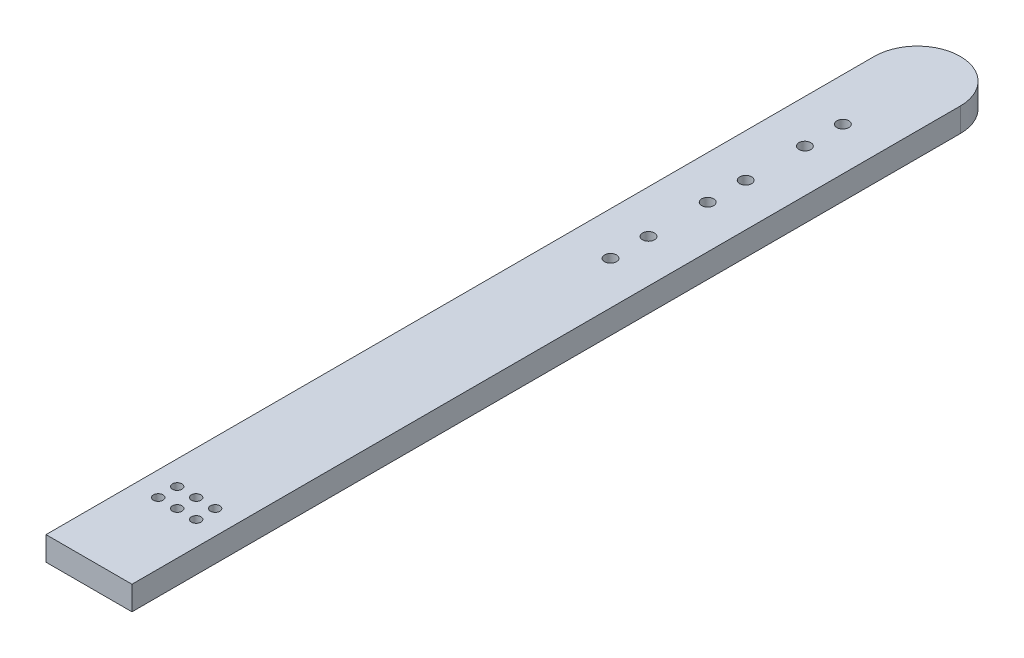
from build123d import *

# Parameters (mm, degrees)
BOSS_EXTRUDE1_DEPTH = 1.6
SKETCH2_R           = 0.3175
SKETCH2_R_2         = 0.4
CUT_EXTRUDE1_DEPTH  = 39.259239815


with BuildPart() as part:
    # Sketch1 → Boss-Extrude1 (new body)
    with BuildSketch(Plane(origin=(0, 0, 0), x_dir=(1, 0, 0), z_dir=(0, 1, 0))):
        with BuildLine():
            Line((-2.875, 35.2425), (-2.875, -20.1575))
            Line((-2.875, -20.1575), (2.875, -20.1575))
            Line((2.875, -20.1575), (2.875, 35.2425))
            ThreePointArc((2.875, 35.2425), (0, 38.1175), (-2.875, 35.2425))
        make_face()
    extrude(amount=BOSS_EXTRUDE1_DEPTH)

    # Sketch2 → Cut-Extrude1 (cut, through all)
    with BuildSketch(Plane.XZ):
        with Locations((1.27, 12.9889)):
            Circle(SKETCH2_R)
        with Locations((0, 12.9889)):
            Circle(SKETCH2_R)
        with Locations((-1.27, 12.9889)):
            Circle(SKETCH2_R)
        with Locations((0, 14.2589)):
            Circle(SKETCH2_R)
        with Locations((-1.27, 14.2589)):
            Circle(SKETCH2_R)
        with Locations((1.27, 14.2589)):
            Circle(SKETCH2_R)
        with Locations((0, -30.2625)):
            Circle(SKETCH2_R_2)
        with Locations((0, -23.7625)):
            Circle(SKETCH2_R_2)
        with Locations((0, -17.2625)):
            Circle(SKETCH2_R_2)
        with Locations((0, -27.7225)):
            Circle(SKETCH2_R_2)
        with Locations((0, -21.2225)):
            Circle(SKETCH2_R_2)
        with Locations((0, -14.7225)):
            Circle(SKETCH2_R_2)
    extrude(amount=-CUT_EXTRUDE1_DEPTH, mode=Mode.SUBTRACT)


solid = part.part
